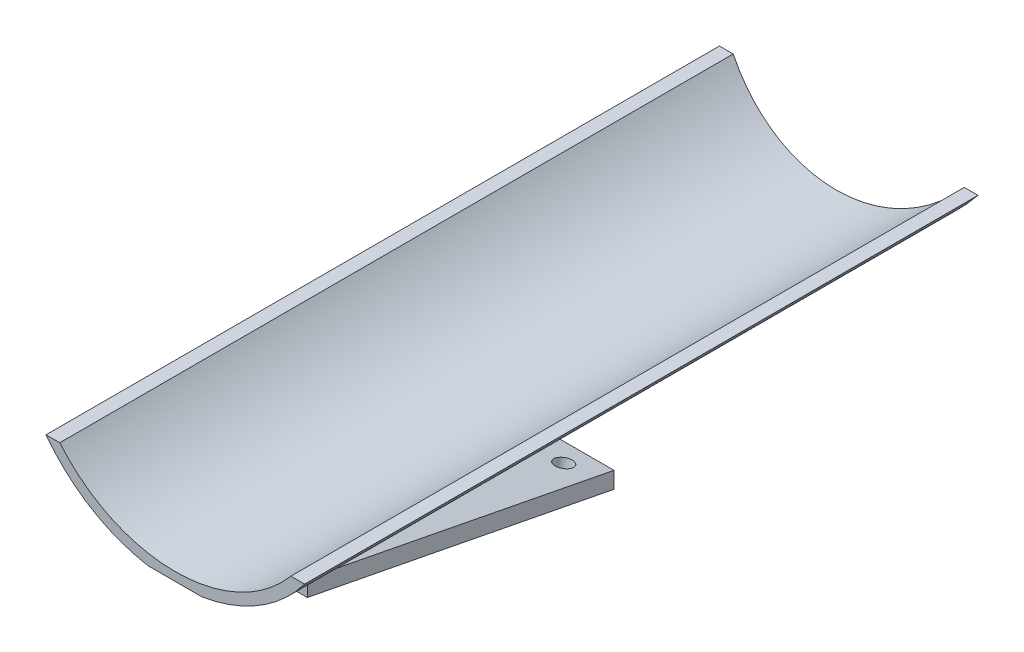
from build123d import *

# Parameters (mm, degrees)
MAIN_DEPTH           = 125
SKETCH2_R            = 25
BEHINDCUT_DEPTH      = 128.808863695
CENTRALSUPPORT_DEPTH = 2.5
SIDESUPPORT_DEPTH    = 12.5
HOLEFIX_REACH        = 127.544
SKETCH6_R            = 1.6
SKETCH9_W            = 5
SKETCH9_H            = 58
BOSS_EXTRUDE4_DEPTH  = 3


with BuildPart() as part:
    # Sketch1 → Main (new body)
    with BuildSketch(Plane.XY):
        with BuildLine():
            Line((-24, 0), (-21.44761059, 0))
            ThreePointArc((-21.44761059, 0), (0, -10), (21.44761059, 0))
            Line((21.44761059, 0), (24, 0))
            ThreePointArc((24, 0), (15.613340762, -7.616861444), (5, -11.580398915))
            Line((5, -11.580398915), (-5, -11.580398915))
            ThreePointArc((-5, -11.580398915), (-15.613340762, -7.616861444), (-24, 0))
        make_face()
    extrude(amount=MAIN_DEPTH)

    # Sketch2 → BehindCut (cut, through all)
    with BuildSketch(Plane(origin=(0, 0, 0), x_dir=(1, 0, 0), z_dir=(0, 0.2249510543438655, 0.9743700647852351))):
        Circle(SKETCH2_R)
    extrude(amount=-BEHINDCUT_DEPTH, mode=Mode.SUBTRACT)

    # Sketch4 → CentralSupport (add, symmetric)
    with BuildSketch(Plane(origin=(0, 0, 0), x_dir=(0, 0, -1), z_dir=(1, 0, 0))):
        Polygon((-113, -11.580398915), (-56.06562336, -11.580398915), (-56.06562336, -24.979884357), (-113, -13.912962625), align=None)
    extrude(amount=CENTRALSUPPORT_DEPTH, both=True)

    # Sketch5 → SideSupport (add, symmetric)
    with BuildSketch(Plane(origin=(0, 0, 0), x_dir=(0, 0, -1), z_dir=(1, 0, 0))):
        Polygon((-56.06562336, -24.979884357), (-113, -13.912962625), (-113, -11.580398915), (-109.277470807, -11.580398915), (-56.06562336, -21.923734272), align=None)
    extrude(amount=SIDESUPPORT_DEPTH, both=True)

    # Sketch6 → HoleFix (cut, up to next)
    with BuildSketch(Plane(origin=(0, -34.571690998, 6.720055984), x_dir=(-1, 0, 0), z_dir=(0, -0.9816271834476653, 0.19080899537653823)), mode=Mode.PRIVATE) as holefix_sk1:
        with Locations((7.5, -55.269153308)):
            Circle(SKETCH6_R)
    holefix_tool1 = extrude(holefix_sk1.sketch, amount=-HOLEFIX_REACH, mode=Mode.PRIVATE) & part.part
    # Sketch6 → HoleFix (cut, up to next)
    with BuildSketch(Plane(origin=(0, -34.571690998, 6.720055984), x_dir=(-1, 0, 0), z_dir=(0, -0.9816271834476653, 0.19080899537653823)), mode=Mode.PRIVATE) as holefix_sk2:
        with Locations((-7.5, -55.269153308)):
            Circle(SKETCH6_R)
    holefix_tool2 = extrude(holefix_sk2.sketch, amount=-HOLEFIX_REACH, mode=Mode.PRIVATE) & part.part
    add(holefix_tool1.solids().sort_by_distance((-7.5, -24.025839, 60.973759))[0], mode=Mode.SUBTRACT)
    add(holefix_tool2.solids().sort_by_distance((7.5, -24.025839, 60.973759))[0], mode=Mode.SUBTRACT)

    # Sketch9 → Boss-Extrude4 (add)
    with BuildSketch(Plane(origin=(0, -34.571690998, 6.720055984), x_dir=(-1, 0, 0), z_dir=(0, -0.9816271834476653, 0.19080899537653823))):
        with Locations((0, -79.269153308)):
            Rectangle(SKETCH9_W, SKETCH9_H)
    extrude(amount=BOSS_EXTRUDE4_DEPTH)


solid = part.part
